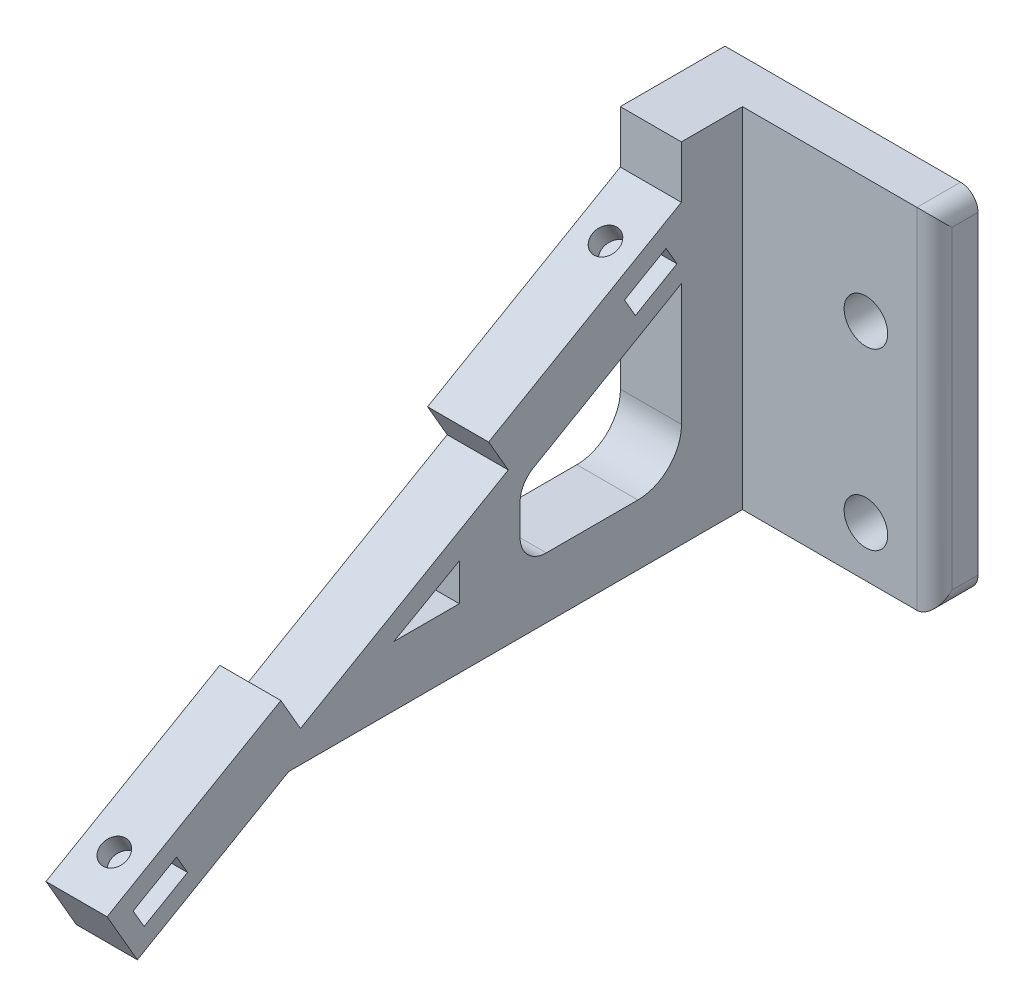
from build123d import *

# Parameters (mm, degrees)
BOSS_EXTRUDE1_DEPTH  = 7
SKETCH2_W            = 29
SKETCH2_H            = 40
SKETCH2_R            = 2.5
BOSS_EXTRUDE2_DEPTH  = 5
FILLET1_R            = 2
SKETCH3_R            = 1.5
CUT_EXTRUDE1_DEPTH   = 7.5
FILLET1_OF_MIRROR1_R = 2
SKETCH4_W            = 36.671322753
SKETCH4_H            = 72.42791828
CUT_EXTRUDE2_DEPTH   = 78.817930688


with BuildPart() as part:
    # Sketch1 → Boss-Extrude1 (new body)
    with BuildSketch(Plane(origin=(0, 0, 0), x_dir=(0, 0, -1), z_dir=(1, 0, 0))):
        Polygon((0, 0), (0, 40), (-7, 40), (-7, 34), (-29.083647797, 21.25), (-26.833647797, 17.352885683), (-50.649346401, 3.602885683), (-52.899346401, 7.5), (-72.817930688, -4), (-69.345498823, -10.014428415), (-52, 0), align=None)
        Polygon((-69.828328815, -4.926142338), (-64.848682743, -2.051142338), (-63.598682743, -4.216205848), (-68.578328815, -7.091205848), align=None, mode=Mode.SUBTRACT)
        Polygon((-39.949930688, 6.884), (-32.449930688, 11.134), (-32.449930688, 6.884), align=None, mode=Mode.SUBTRACT)
        with BuildLine():
            Line((-6.98, 25.947), (-6.98, 11.947))
            ThreePointArc((-6.98, 11.947), (-8.444466094, 8.411466094), (-11.98, 6.947))
            Line((-11.98, 6.947), (-22.48, 6.947))
            ThreePointArc((-22.48, 6.947), (-24.601320344, 7.825679656), (-25.48, 9.947))
            Line((-25.48, 9.947), (-25.48, 13.505607896))
            ThreePointArc((-25.48, 13.505607896), (-25.078135635, 15.007043949), (-23.98, 16.107))
            Line((-23.98, 16.107), (-6.98, 25.947))
        make_face(mode=Mode.SUBTRACT)
        Polygon((-13.512490144, 27.556681889), (-8.752389988, 30.311939862), (-7.5, 28.148257973), (-12.260100157, 25.393), align=None, mode=Mode.SUBTRACT)
    boss_extrude1 = extrude(amount=-BOSS_EXTRUDE1_DEPTH)

    # Sketch2 → Boss-Extrude2 (add)
    with BuildSketch(Plane(origin=(0, 0, 0), x_dir=(-1, 0, 0), z_dir=(0, 0, -1))):
        with Locations((14.5, 20)):
            Rectangle(SKETCH2_W, SKETCH2_H)
        with Locations((21.15335434, 25.78)):
            Circle(SKETCH2_R, mode=Mode.SUBTRACT)
        with Locations((21.15335434, 5.78)):
            Circle(SKETCH2_R, mode=Mode.SUBTRACT)
    boss_extrude2 = extrude(amount=BOSS_EXTRUDE2_DEPTH)

    # Fillet1
    fillet1_edges = [part.edges().sort_by_distance(p)[0] for p in [
        (-29, 20, 0),
        (-29, 0, -2.5),
        (-29, 40, -2.5),
    ]]
    fillet(fillet1_edges, radius=FILLET1_R)

    # Sketch3 → Cut-Extrude1 (cut)
    with BuildSketch(Plane(origin=(0, 28.531088913, 16.472431864), x_dir=(1, 0, 0), z_dir=(0, 0.866025404, 0.5))):
        with Locations((-3.5, 4.937822174)):
            Circle(SKETCH3_R)
        with Locations((-3.5, -60.062177826)):
            Circle(SKETCH3_R)
    cut_extrude1 = extrude(amount=-CUT_EXTRUDE1_DEPTH, mode=Mode.SUBTRACT)

    # Mirror1: Boss-Extrude1, Boss-Extrude2, Cut-Extrude1 across plane
    add(boss_extrude1.mirror(Plane(origin=(0, 0, 0), x_dir=(0, 0, 1), z_dir=(1, 0, 0))))
    add(boss_extrude2.mirror(Plane(origin=(0, 0, 0), x_dir=(0, 0, 1), z_dir=(1, 0, 0))))
    add(cut_extrude1.mirror(Plane(origin=(0, 0, 0), x_dir=(0, 0, 1), z_dir=(1, 0, 0))), mode=Mode.SUBTRACT)

    # Fillet1 of Mirror1
    fillet1_of_mirror1_edges = [part.edges().sort_by_distance(p)[0] for p in [
        (29, 20, 0),
        (29, 0, -2.5),
        (29, 40, -2.5),
    ]]
    fillet(fillet1_of_mirror1_edges, radius=FILLET1_OF_MIRROR1_R)

    # Sketch4 → Cut-Extrude2 (cut, through all)
    with BuildSketch(Plane(origin=(0, 0, -5), x_dir=(-1, 0, 0), z_dir=(0, 0, -1))):
        with Locations((18.335661377, 3.78604086)):
            Rectangle(SKETCH4_W, SKETCH4_H)
    extrude(amount=-CUT_EXTRUDE2_DEPTH, mode=Mode.SUBTRACT)


solid = part.part
